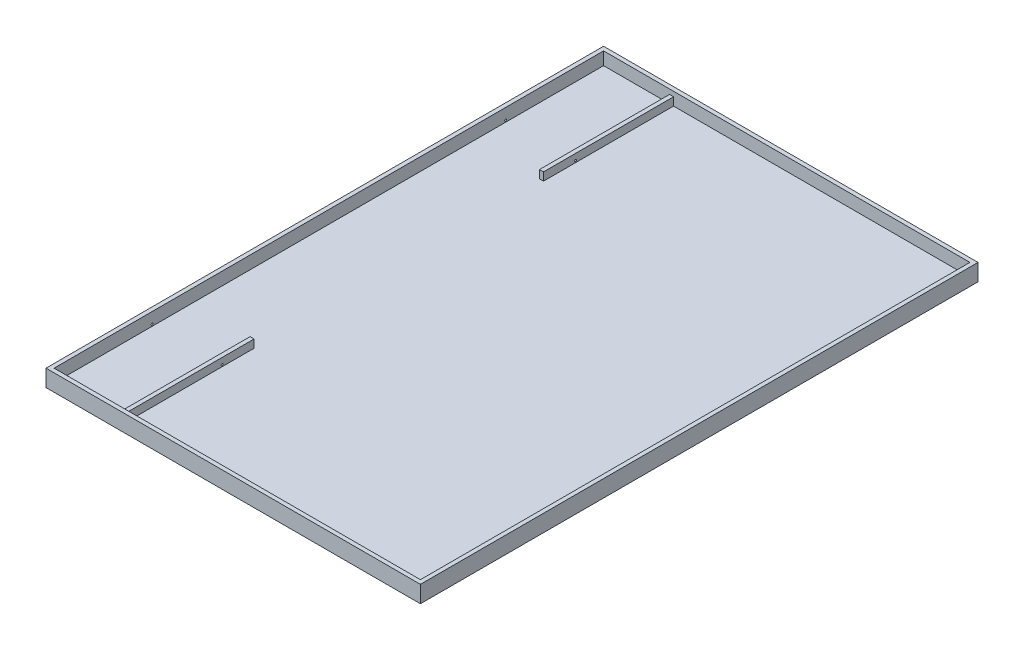
from build123d import *

# Parameters (mm, degrees)
ESQUISSE1_W             = 2000
ESQUISSE1_H             = 3000
BOSS_EXTRU_1_DEPTH      = 22
ESQUISSE2_W             = 2044
ESQUISSE2_H             = 3044
ESQUISSE2_W_2           = 2000
ESQUISSE2_H_2           = 3000
BOSS_EXTRU_2_DEPTH      = 70
BOSS_EXTRU_2_DEPTH_BACK = 22
ESQUISSE3_W             = 22
ESQUISSE3_H             = 710
BOSS_EXTRU_3_DEPTH      = 44
ESQUISSE4_R             = 5
ENL_V_MAT_EXTRU_1_DEPTH = 405


with BuildPart() as part:
    # Esquisse1 → Boss.-Extru.1 (new body)
    with BuildSketch(Plane(origin=(0, 0, 0), x_dir=(1, 0, 0), z_dir=(0, 1, 0))):
        Rectangle(ESQUISSE1_W, ESQUISSE1_H)
    extrude(amount=-BOSS_EXTRU_1_DEPTH)

    # Esquisse2 → Boss.-Extru.2 (add, two sides)
    with BuildSketch(Plane(origin=(0, 0, 0), x_dir=(1, 0, 0), z_dir=(0, 1, 0))) as boss_extru_2_sk:
        Rectangle(ESQUISSE2_W, ESQUISSE2_H)
        Rectangle(ESQUISSE2_W_2, ESQUISSE2_H_2, mode=Mode.SUBTRACT)
    extrude(amount=BOSS_EXTRU_2_DEPTH)
    extrude(boss_extru_2_sk.sketch, amount=-BOSS_EXTRU_2_DEPTH_BACK)

    # Esquisse3 → Boss.-Extru.3 (add)
    with BuildSketch(Plane(origin=(0, 0, 0), x_dir=(1, 0, 0), z_dir=(0, 1, 0))):
        with Locations((-629, 1145)):
            Rectangle(ESQUISSE3_W, ESQUISSE3_H)
    boss_extru_3 = extrude(amount=BOSS_EXTRU_3_DEPTH)

    # Esquisse4 → Enlèv. mat.-Extru.1 (cut, through all)
    with BuildSketch(Plane(origin=(-618, 0, 0), x_dir=(0, 0, -1), z_dir=(1, 0, 0))):
        with Locations((965, 10)):
            Circle(ESQUISSE4_R)
    enl_v_mat_extru_1 = extrude(amount=-ENL_V_MAT_EXTRU_1_DEPTH, mode=Mode.SUBTRACT)

    # Symétrie1: Boss.-Extru.3, Enlèv. mat.-Extru.1 across plane
    add(boss_extru_3.mirror(Plane.XY))
    add(enl_v_mat_extru_1.mirror(Plane.XY), mode=Mode.SUBTRACT)


solid = part.part
